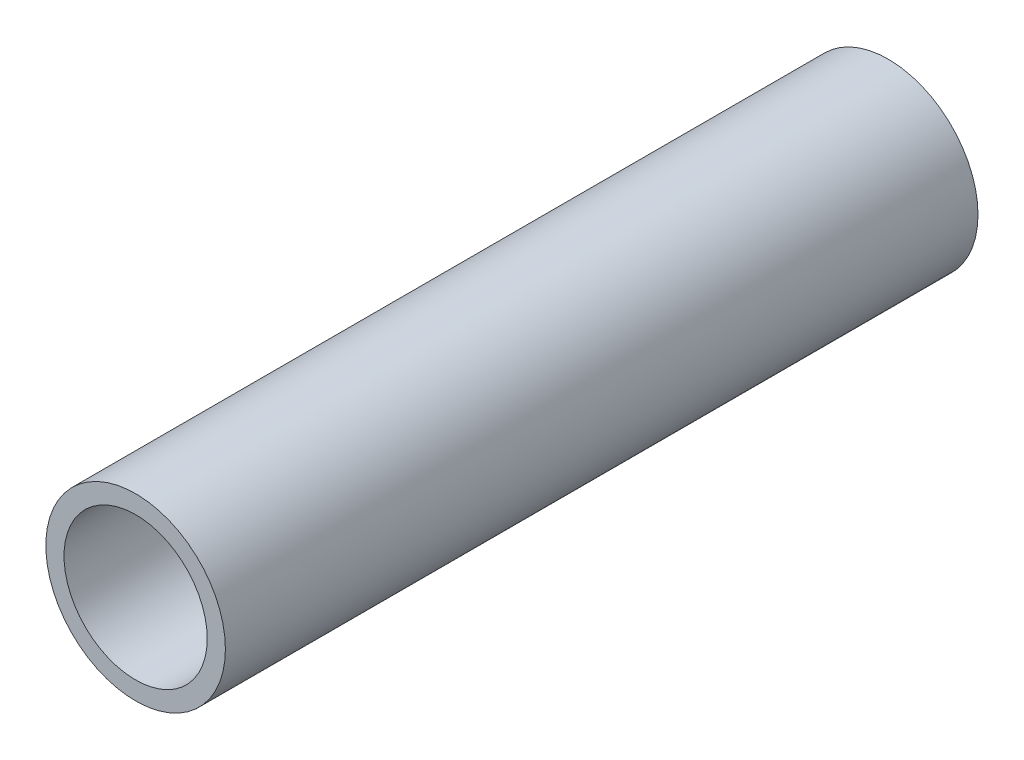
from build123d import *

# Parameters (mm, degrees)
SKETCH1_R           = 16.7005
SKETCH1_R_2         = 13.3223
EXTRUDE_THIN1_DEPTH = 70


with BuildPart() as part:
    # Sketch1 → Extrude-Thin1 (new body, symmetric)
    with BuildSketch(Plane.XY):
        Circle(SKETCH1_R)
        Circle(SKETCH1_R_2, mode=Mode.SUBTRACT)
    extrude(amount=EXTRUDE_THIN1_DEPTH, both=True)


solid = part.part
